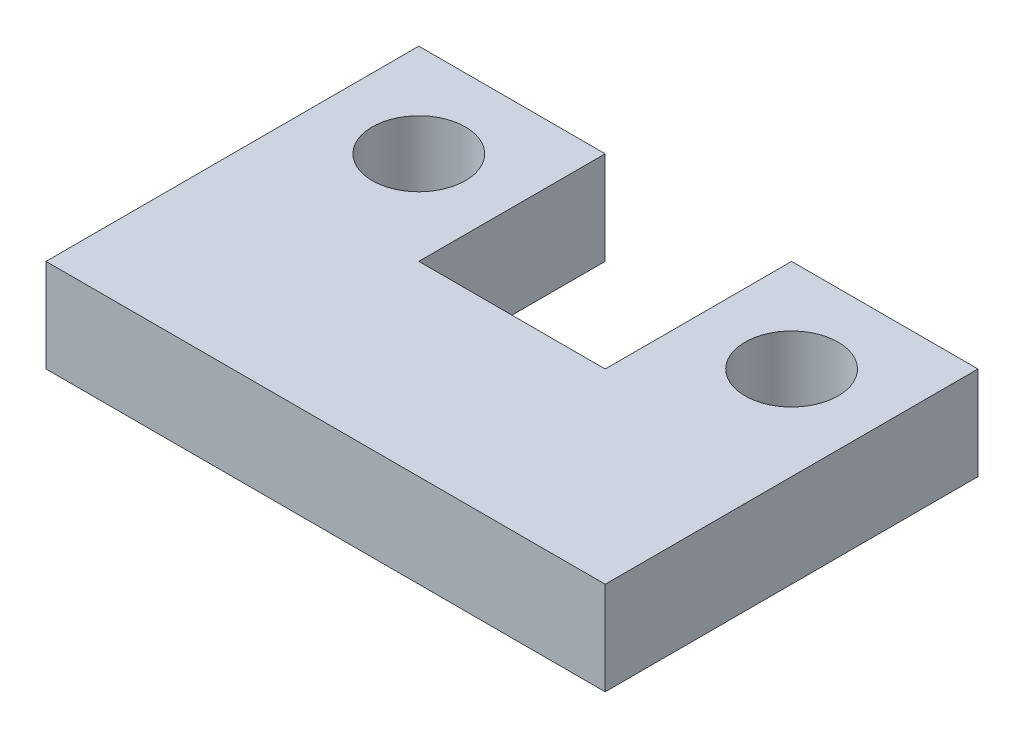
from build123d import *

# Parameters (mm, degrees)
BOSS_EXTRUDE1_DEPTH = 20
SKETCH4_R           = 10
CUT_EXTRUDE1_DEPTH  = 20


with BuildPart() as part:
    # Sketch2 → Boss-Extrude1 (new body)
    with BuildSketch(Plane(origin=(0, 0, 0), x_dir=(1, 0, 0), z_dir=(0, 1, 0))):
        Polygon((0, 0), (120, 0), (120, 80), (80, 80), (80, 40), (40, 40), (40, 80), (0, 80), align=None)
    extrude(amount=BOSS_EXTRUDE1_DEPTH)

    # Sketch4 → Cut-Extrude1 (cut)
    with BuildSketch(Plane.XZ):
        with Locations((20, -60)):
            Circle(SKETCH4_R)
        with Locations((100, -60)):
            Circle(SKETCH4_R)
    extrude(amount=-CUT_EXTRUDE1_DEPTH, mode=Mode.SUBTRACT)


solid = part.part
